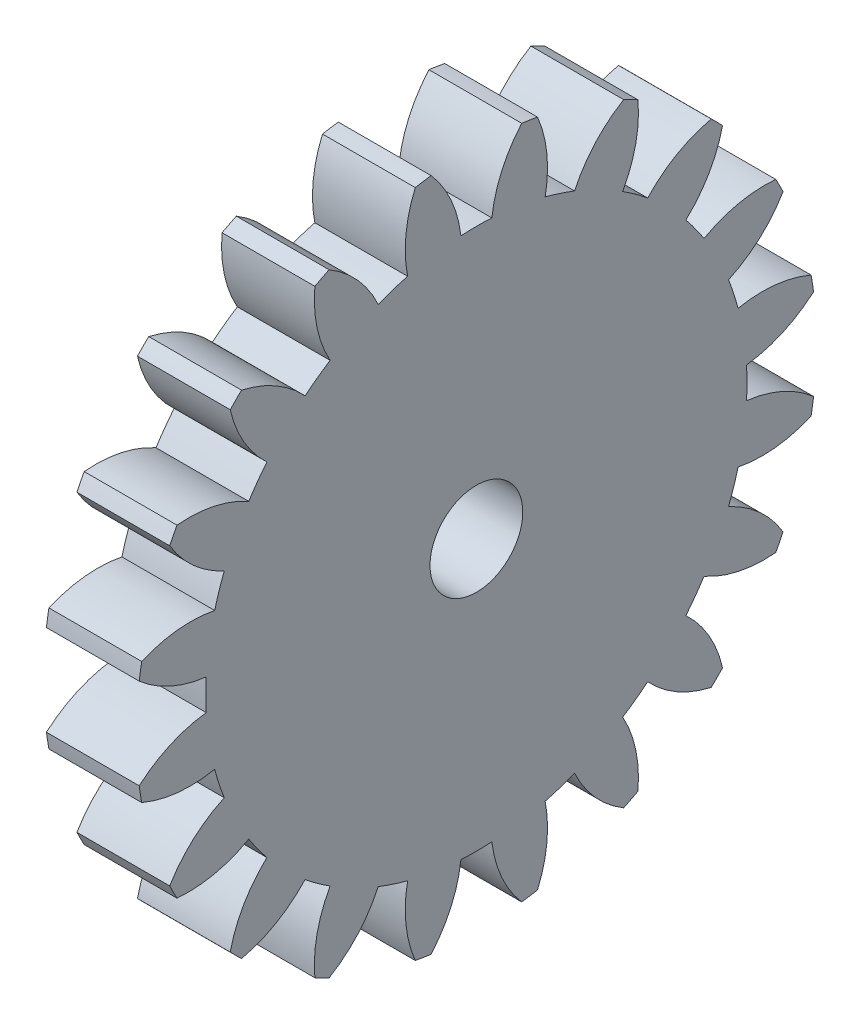
from build123d import *

# Parameters (mm, degrees)
BASPROSKE_W     = 3
BASPROSKE_H     = 11
TOOTHCUT_DEPTH  = 16.842979518
TEETHCUTS_COUNT = 20
TEETHCUTS_ANGLE = 342
BORSKE_R        = 1.5
BORE_DEPTH      = 50.0000508


with BuildPart() as part:
    # BasProSke → Base-Revolve (revolve)
    with BuildSketch(Plane(origin=(0, 0, 0), x_dir=(1, 0, 0), z_dir=(0, 1, 0)), mode=Mode.PRIVATE) as base_revolve_sk:
        with Locations((1.5, 5.5)):
            Rectangle(BASPROSKE_W, BASPROSKE_H)
    revolve(base_revolve_sk.sketch.rotate(Axis((-10, 0, 0), (1, 0, 0)), 180), axis=Axis((-10, 0, 0), (1, 0, 0)))

    # TooCutSke → ToothCut (cut, through all)
    with BuildSketch(Plane(origin=(0, 0, 0), x_dir=(0, 0, -1), z_dir=(1, 0, 0))):
        with BuildLine():
            ThreePointArc((0.499924007, 8.734705318), (0, 8.749), (-0.499924007, 8.734705318))
            ThreePointArc((-0.499924007, 8.734705318), (-0.824302243, 9.905497836), (-1.485192705, 10.924909509))
            ThreePointArc((-1.485192705, 10.924909509), (0, 11.0254), (1.485192705, 10.924909509))
            ThreePointArc((1.485192705, 10.924909509), (0.824302243, 9.905497836), (0.499924007, 8.734705318))
        make_face()
    toothcut = extrude(amount=TOOTHCUT_DEPTH, mode=Mode.SUBTRACT)

    # TeethCuts: ToothCut ×20 about axis
    teethcuts_axis = Axis((-10, 0, 0), (1, 0, 0))
    for i in range(1, TEETHCUTS_COUNT):
        add(toothcut.rotate(teethcuts_axis, i * TEETHCUTS_ANGLE / (TEETHCUTS_COUNT - 1)), mode=Mode.SUBTRACT)

    # BorSke → Bore (cut, symmetric)
    with BuildSketch(Plane(origin=(0, 0, 0), x_dir=(0, 0, -1), z_dir=(1, 0, 0))):
        with Locations(Location((0, 0, 0), (0, 0, 180))):
            Circle(BORSKE_R)
    extrude(amount=BORE_DEPTH, both=True, mode=Mode.SUBTRACT)


solid = part.part
